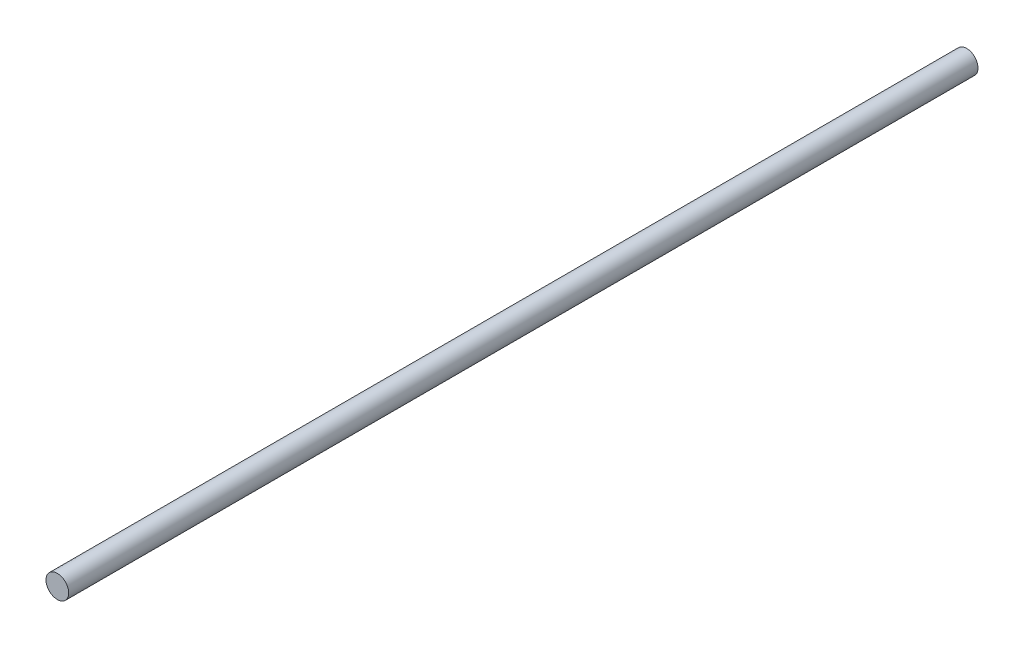
from build123d import *

# Parameters (mm, degrees)
ESQUISSE1_R        = 3.75
BOSS_EXTRU_1_DEPTH = 300


with BuildPart() as part:
    # Esquisse1 → Boss.-Extru.1 (new body)
    with BuildSketch(Plane.XY):
        Circle(ESQUISSE1_R)
    extrude(amount=BOSS_EXTRU_1_DEPTH)


solid = part.part
